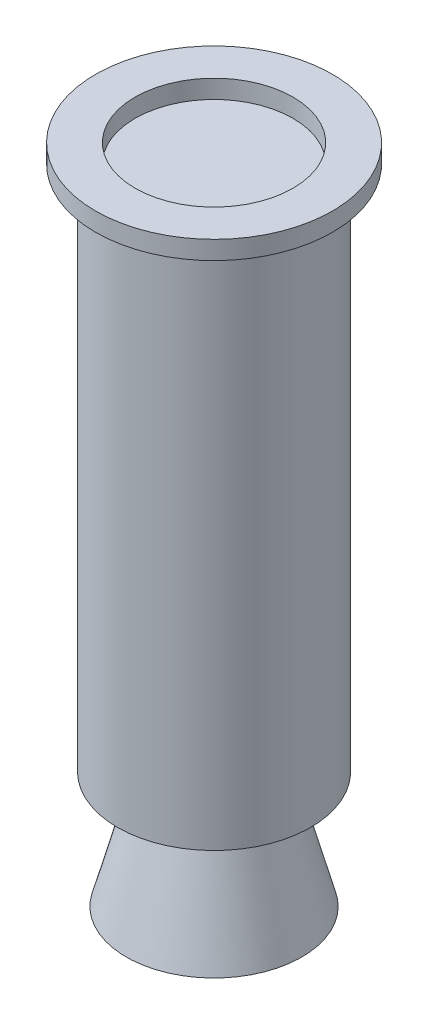
from build123d import *

# Parameters (mm, degrees)
CUT_EXTRUDE1_DEPTH      = 42.656
CUT_EXTRUDE1_DEPTH_BACK = 42.656


with BuildPart() as part:
    # Sketch1 → CHAMBER GEOMETRY (revolve)
    with BuildSketch(Plane.XY):
        with BuildLine():
            Line((0, 0), (-38.1, 0))
            Line((-38.1, 0), (-38.1, -157.332041631))
            Line((-38.1, -157.332041631), (-19.331058169, -208.113159893))
            ThreePointArc((-19.331058169, -208.113159893), (-18.081947937, -212.694672543), (-17.653, -217.424))
            ThreePointArc((-17.653, -217.424), (-17.710909205, -218.322313303), (-17.888255676, -219.204848569))
            Line((-17.888255676, -219.204848569), (-41.656, -307.594))
            Line((-41.656, -307.594), (0, -307.594))
            Line((0, -307.594), (0, 0))
        make_face()
    revolve(axis=Axis((0, 0, 0), (0, -1, 0)))

    # Sketch3 → CF REVOLVE (revolve)
    with BuildSketch(Plane.XY):
        with BuildLine():
            ThreePointArc((19.052545295, -218.891772388), (18.923521318, -218.163557003), (18.923, -217.424))
            ThreePointArc((18.923, -217.424), (19.548451138, -212.730087586), (20.601058169, -208.113159893))
            Line((20.601058169, -208.113159893), (19.331058169, -208.113159893))
            ThreePointArc((19.331058169, -208.113159893), (18.081947937, -212.694672543), (17.653, -217.424))
            ThreePointArc((17.653, -217.424), (17.710909205, -218.322313303), (17.888255676, -219.204848569))
            Line((17.888255676, -219.204848569), (19.254262016, -224.284848569))
            Line((19.254262016, -224.284848569), (20.418551634, -223.971772388))
            Line((20.418551634, -223.971772388), (19.052545295, -218.891772388))
        make_face()
        Polygon((24.927703857, -196.634205845), (23.736466151, -196.193918747), (19.331058169, -208.113159893), (20.601058169, -208.113159893), align=None)
        Polygon((39.453969902, -157.332041631), (38.1, -157.332041631), (23.736466151, -196.193918747), (24.927703857, -196.634205845), align=None)
        Polygon((39.453969902, -132.003733221), (37.984578859, -132.003733221), (38.1, -157.332041631), (39.453969902, -157.332041631), align=None)
    revolve(axis=Axis((0, -217.424, 0), (0, 1, 0)))

    # Sketch4 → RTV/EPOXY (revolve)
    with BuildSketch(Plane.XY):
        Polygon((18.923521318, -218.163557003), (18.923521318, -213.083557003), (20.955521318, -213.083557003), (20.955521318, -221.211557003), (18.923521318, -221.211557003), align=None)
    revolve(axis=Axis((0, -217.424, 0), (0, -1, 0)))

    # Sketch6 → Cut-Extrude1 (cut, two sides)
    with BuildSketch(Plane.XY) as cut_extrude1_sk:
        Polygon((41.656, -307.594), (21.870533279, -234.014421294), (-21.870533279, -234.014421294), (-41.656, -307.594), align=None)
    extrude(amount=CUT_EXTRUDE1_DEPTH, mode=Mode.SUBTRACT)
    extrude(cut_extrude1_sk.sketch, amount=-CUT_EXTRUDE1_DEPTH_BACK, mode=Mode.SUBTRACT)

    # Sketch7 → DASHED RTV/EPOXY (revolve)
    with BuildSketch(Plane(origin=(0, 0, 0), x_dir=(0, 0, -1), z_dir=(1, 0, 0))):
        Polygon((-21.870533279, -234.014421294), (-42.359549747, -310.214421294), (0, -310.214421294), (0, -234.014421294), align=None)
    revolve(axis=Axis((0, -310.214421294, 0), (0, 1, 0)))

    # Sketch10 → DASHED RTV/EPOXY OVERHANG (revolve)
    with BuildSketch(Plane.XY):
        Polygon((21.870533279, -204.745135906), (34.75998975, -170.032041631), (34.75998975, -250.042041631), (26.180115655, -250.042041631), (21.870533279, -234.014421294), align=None)
    revolve(axis=Axis((0, -221.211557003, 0), (0, 1, 0)))

    # Sketch11 → BLUE TUBE (revolve)
    with BuildSketch(Plane.XY):
        Polygon((34.75998975, -253.947859685), (27.23033049, -253.947859685), (25.282654818, -253.947859685), (25.282654818, -250.042041631), (27.23033049, -250.042041631), (34.75998975, -250.042041631), (38.1, -250.042041631), (38.1, -132.003733221), (38.1, 0), (38.1, 8.89), (57.15, 8.89), (57.15, 0), (46.584796967, 0), (46.584796967, -253.947859685), align=None)
    revolve(axis=Axis((0, 0, 0), (0, -1, 0)))


solid = part.part
